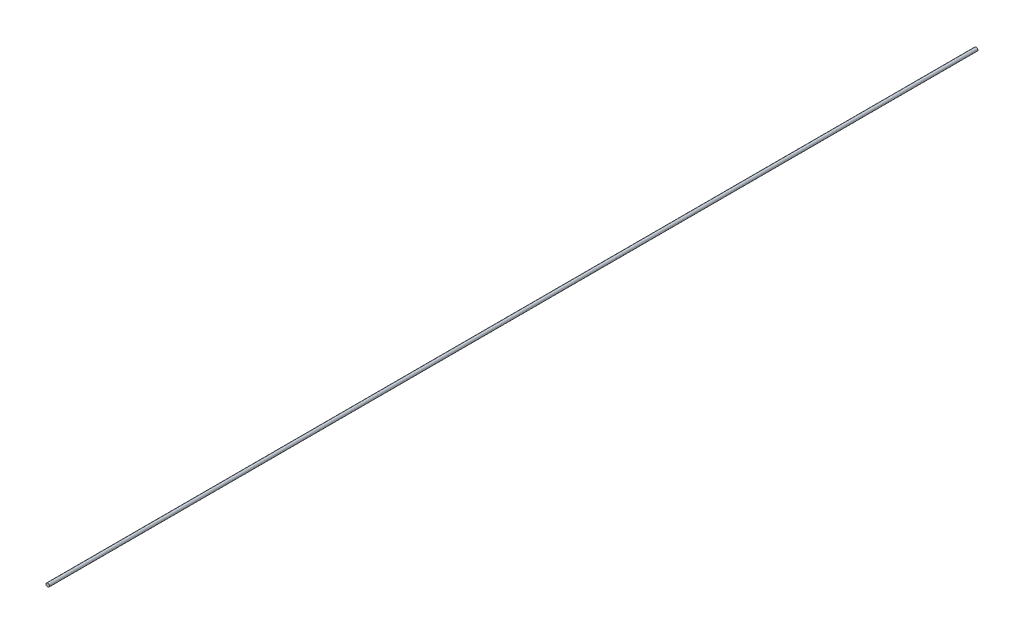
from build123d import *

# Parameters (mm, degrees)
SKETCH1_R           = 3.8
BOSS_EXTRUDE1_DEPTH = 2072


with BuildPart() as part:
    # Sketch1 → Boss-Extrude1 (new body)
    with BuildSketch(Plane.XY):
        Circle(SKETCH1_R)
    extrude(amount=BOSS_EXTRUDE1_DEPTH)


solid = part.part
